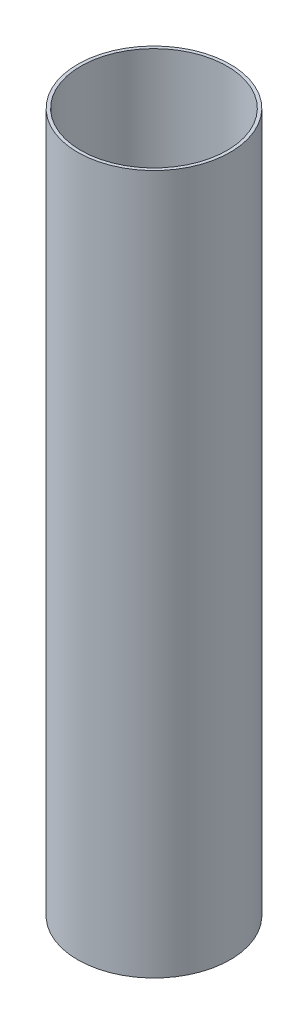
from build123d import *

# Parameters (mm, degrees)
SKETCH1_R           = 24
SKETCH1_R_2         = 23
BOSS_EXTRUDE1_DEPTH = 220


with BuildPart() as part:
    # Sketch1 → Boss-Extrude1 (new body)
    with BuildSketch(Plane(origin=(0, 0, 0), x_dir=(1, 0, 0), z_dir=(0, 1, 0))):
        Circle(SKETCH1_R)
        Circle(SKETCH1_R_2, mode=Mode.SUBTRACT)
    extrude(amount=BOSS_EXTRUDE1_DEPTH)


solid = part.part
